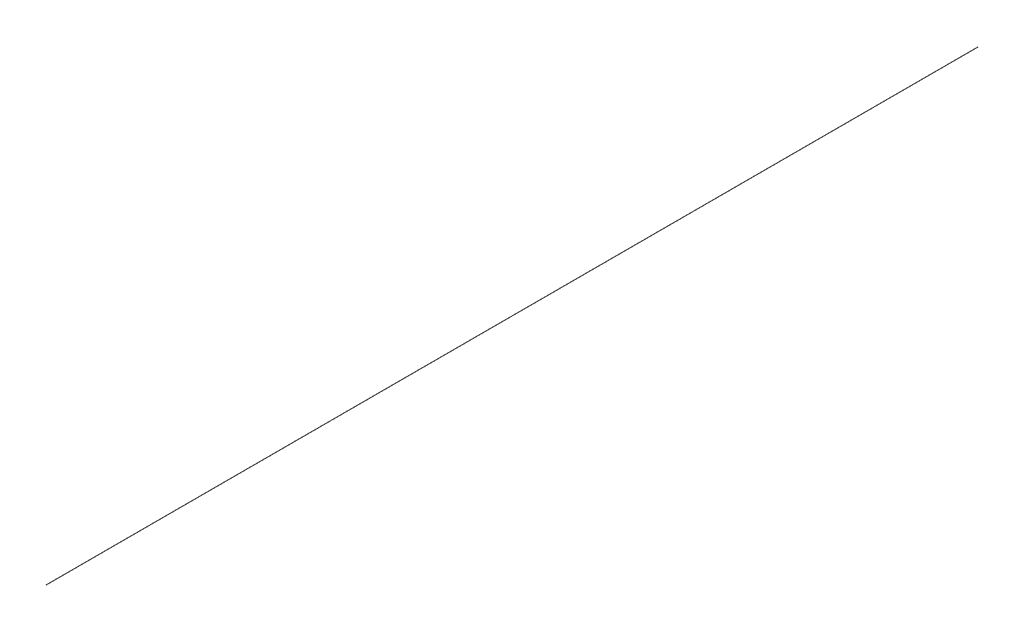
from build123d import *

# Parameters (mm, degrees)
SKETCH1_R           = 3.175
BOSS_EXTRUDE1_DEPTH = 26193.8


with BuildPart() as part:
    # Sketch1 → Boss-Extrude1 (new body)
    with BuildSketch(Plane.XY):
        Circle(SKETCH1_R)
    extrude(amount=-BOSS_EXTRUDE1_DEPTH)


solid = part.part
